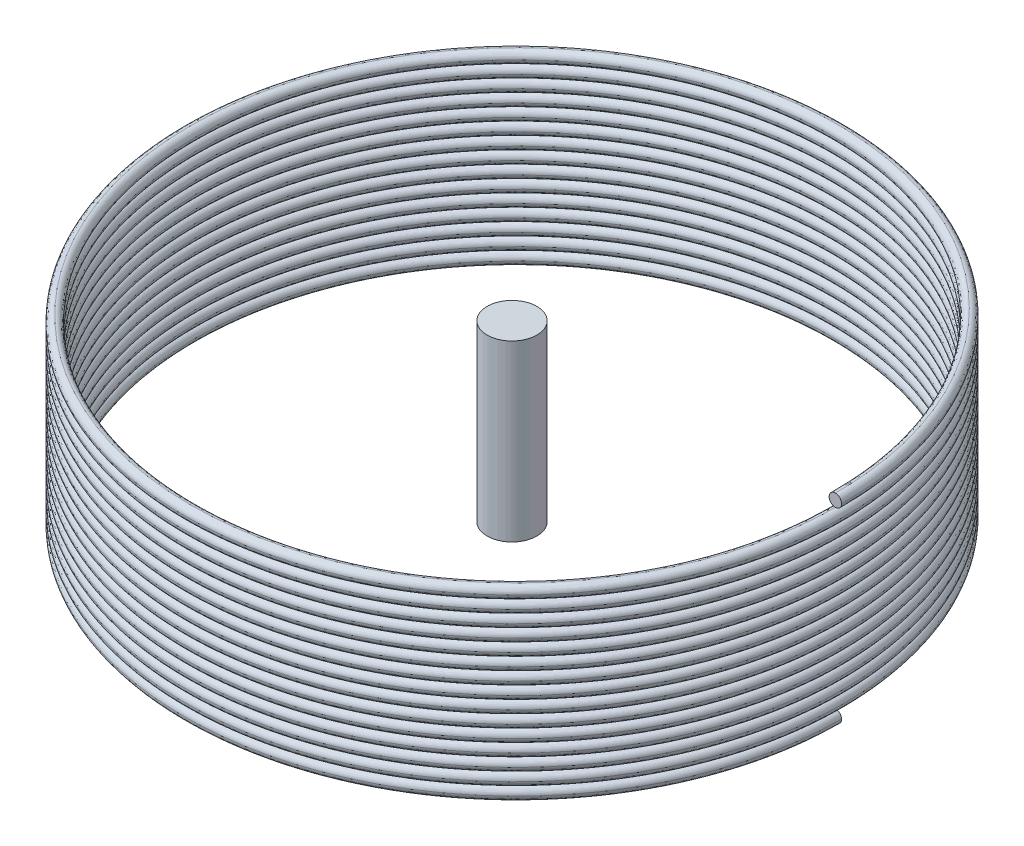
from build123d import *

# Parameters (mm, degrees)
BALAYAGE1_PITCH       = 0.5
BALAYAGE1_HEIGHT      = 7.5
BALAYAGE1_RADIUS      = 13
BALAYAGE1_START_ANGLE = 90
ESQUISSE2_R           = 0.25
ESQUISSE3_R           = 1
BOSS_EXTRU_1_DEPTH    = 7


with BuildPart() as part:
    # Balayage1: sweep along a helix
    with BuildLine() as balayage1_path:
        add(Helix(BALAYAGE1_PITCH, BALAYAGE1_HEIGHT, BALAYAGE1_RADIUS, center=(0, 0, 0), direction=(0, 1, 0), lefthand=True, mode=Mode.PRIVATE).rotate(Axis((0, 0, 0), (0, 1, 0)), BALAYAGE1_START_ANGLE))
    # Esquisse2 → Balayage1 (sweep)
    with BuildSketch(Plane.XY):
        with Locations((-13, 0)):
            Circle(ESQUISSE2_R)
    sweep(path=balayage1_path.line, is_frenet=True)


with BuildPart() as body_2:
    # Esquisse3 → Boss.-Extru.1 (new body)
    with BuildSketch(Plane(origin=(0, 0, 0), x_dir=(1, 0, 0), z_dir=(0, 1, 0))):
        with Locations(Location((0, 0, 0), (0, 0, 270))):  # turned: the seam where the file's is
            Circle(ESQUISSE3_R)
    extrude(amount=BOSS_EXTRU_1_DEPTH)


solid = Compound([part.part, body_2.part])
